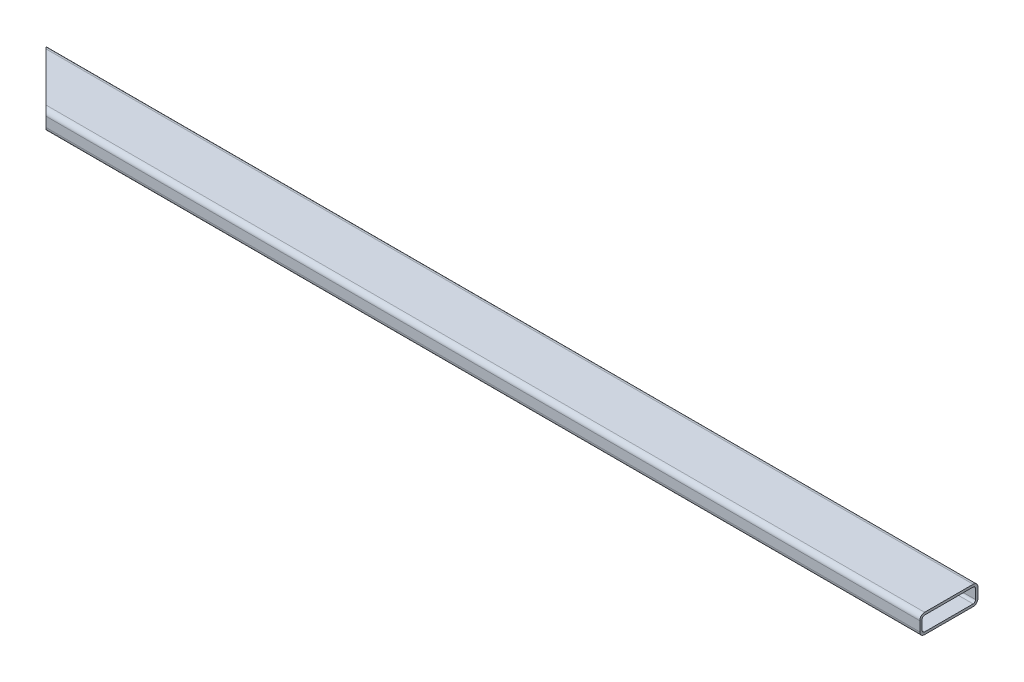
from build123d import *

# Parameters (mm, degrees)
SKETCH1_W           = 76.2
SKETCH1_H           = 25.4
BOSS_EXTRUDE1_DEPTH = 1219.2
FILLET1_R           = 6.35
SHELL1_T            = -3.175
CUT_EXTRUDE1_DEPTH  = 25.4


with BuildPart() as part:
    # Sketch1 → Boss-Extrude1 (new body)
    with BuildSketch(Plane(origin=(0, 0, 0), x_dir=(0, 0, -1), z_dir=(1, 0, 0))):
        with Locations((38.1, 12.7)):
            Rectangle(SKETCH1_W, SKETCH1_H)
    extrude(amount=BOSS_EXTRUDE1_DEPTH)

    # Fillet1
    fillet1_edges = [part.edges().sort_by_distance(p)[0] for p in [
        (609.6, 25.4, 0),
        (609.6, 25.4, -76.2),
        (609.6, 0, -76.2),
        (609.6, 0, 0),
    ]]
    fillet(fillet1_edges, radius=FILLET1_R)

    # Shell1
    shell1_openings = [part.faces().sort_by_distance(p)[0] for p in [
        (1219.2, 12.7, -38.1),
        (0, 12.7, -38.1),
    ]]
    offset(amount=SHELL1_T, openings=shell1_openings, kind=Kind.INTERSECTION)

    # Sketch2 → Cut-Extrude1 (cut)
    with BuildSketch(Plane(origin=(0, 25.4, 0), x_dir=(1, 0, 0), z_dir=(0, 1, 0))):
        Polygon((0, 76.2), (76.2, 0), (0, 0), align=None)
    extrude(amount=-CUT_EXTRUDE1_DEPTH, mode=Mode.SUBTRACT)


solid = part.part
